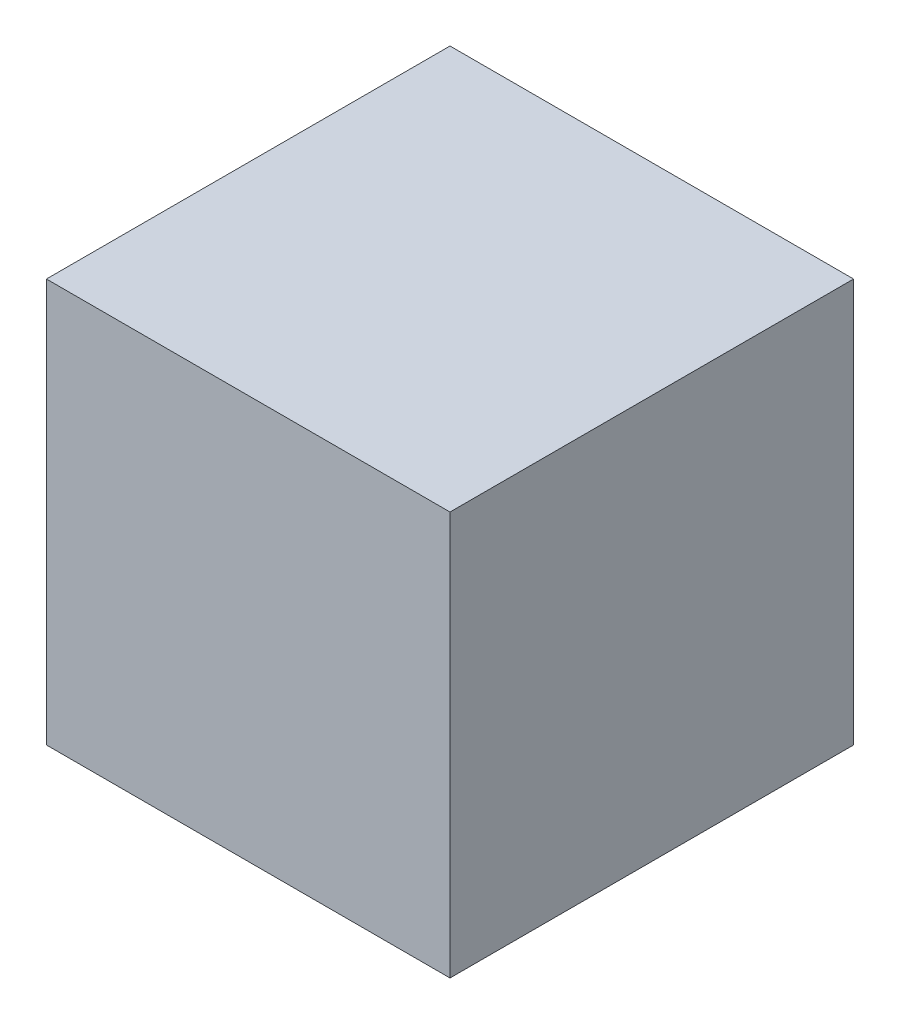
from build123d import *

# Parameters (mm, degrees)
SKETCH_1_W      = 25.4
SKETCH_1_H      = 25.4
EXTRUDE_1_DEPTH = 25.4


with BuildPart() as part:
    # 草图1 → 凸台-拉伸1 (new body)
    with BuildSketch(Plane(origin=(0, 0, 0), x_dir=(1, 0, 0), z_dir=(0, 1, 0))):
        Rectangle(SKETCH_1_W, SKETCH_1_H)
    extrude(amount=EXTRUDE_1_DEPTH)


solid = part.part
